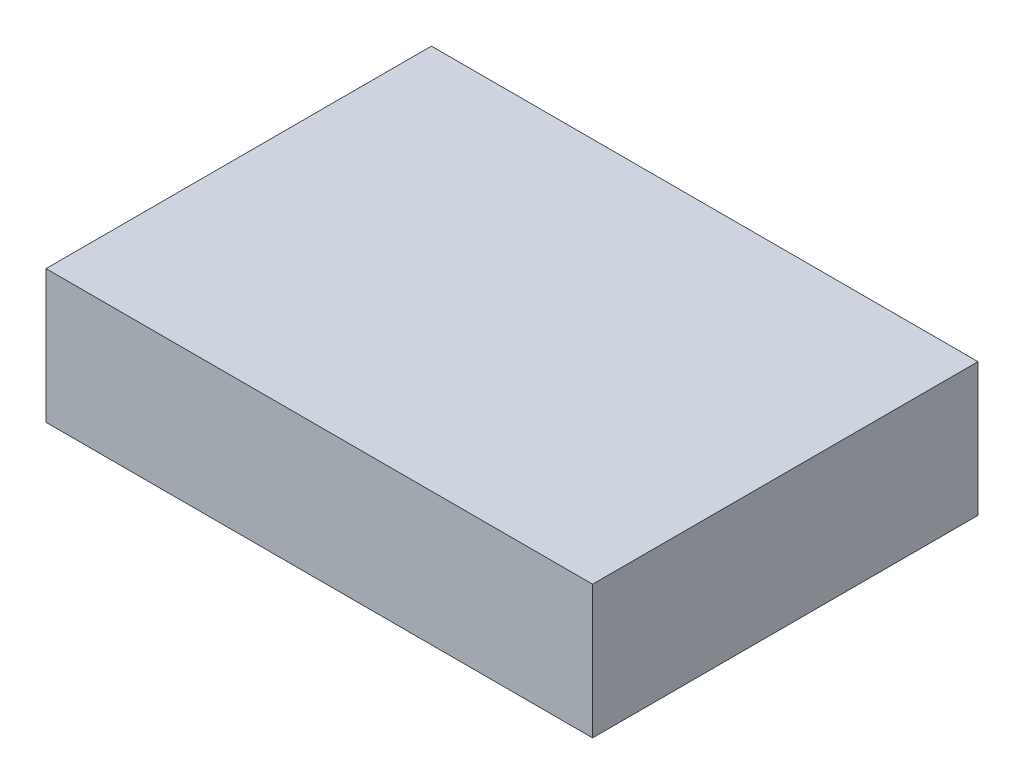
from build123d import *

# Parameters (mm, degrees)
SKETCH1_W           = 78
SKETCH1_H           = 55
BOSS_EXTRUDE1_DEPTH = 19


with BuildPart() as part:
    # Sketch1 → Boss-Extrude1 (new body)
    with BuildSketch(Plane(origin=(0, 0, 0), x_dir=(1, 0, 0), z_dir=(0, 1, 0))):
        with Locations((-39, -27.5)):
            Rectangle(SKETCH1_W, SKETCH1_H)
    extrude(amount=BOSS_EXTRUDE1_DEPTH)


solid = part.part
